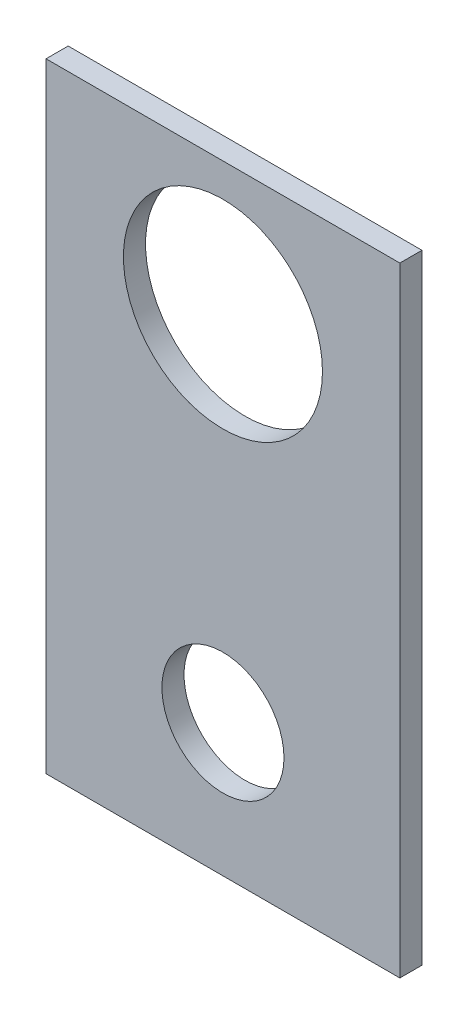
from build123d import *

# Parameters (mm, degrees)
SKETCH1_W           = 50.8
SKETCH1_H           = 88.9
SKETCH1_R           = 14.2875
SKETCH1_R_2         = 8.763
BOSS_EXTRUDE1_DEPTH = 3.175


with BuildPart() as part:
    # Sketch1 → Boss-Extrude1 (new body)
    with BuildSketch(Plane.XY):
        with Locations((25.4, 44.45)):
            Rectangle(SKETCH1_W, SKETCH1_H)
        with Locations((25.4, 69.85)):
            Circle(SKETCH1_R, mode=Mode.SUBTRACT)
        with Locations((25.4, 19.05)):
            Circle(SKETCH1_R_2, mode=Mode.SUBTRACT)
    extrude(amount=BOSS_EXTRUDE1_DEPTH)


solid = part.part
